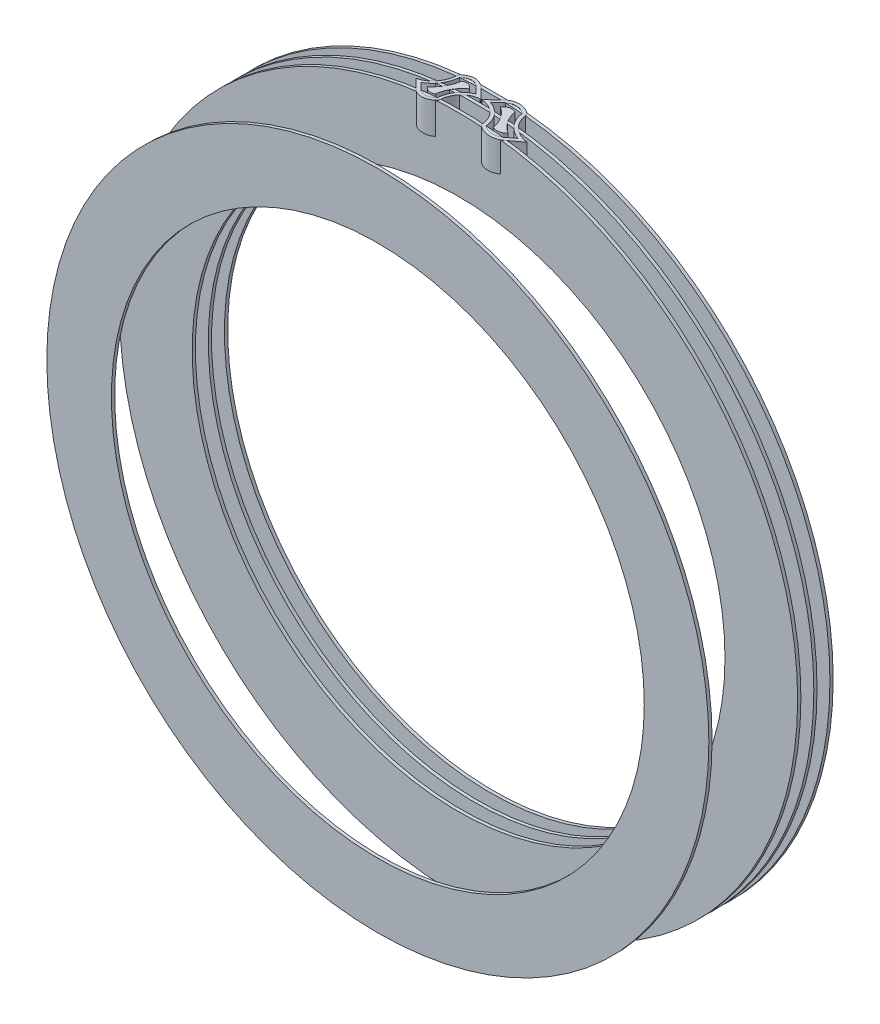
from build123d import *

# Parameters (mm, degrees)
SKETCH1_R                = 13.0175
SKETCH1_R_2              = 12.3825
SKETCH1_R_3              = 10.4775
BOSS_EXTRUDE1_DEPTH      = 0.0635
BOSS_EXTRUDE3_REACH      = 30.259
BOSS_EXTRUDE3_END_RADIUS = 13.335
SKETCH4_R                = 13.335
SKETCH4_R_2              = 10.4775
BOSS_EXTRUDE4_DEPTH      = 0.0635
SKETCH9_R                = 13.335
SKETCH9_R_2              = 10.4775
BOSS_EXTRUDE5_DEPTH      = 0.0635
SKETCH10_R               = 13.335
SKETCH10_R_2             = 10.4775
BOSS_EXTRUDE6_DEPTH      = 0.0635


with BuildPart() as part:
    # Sketch1 → Boss-Extrude1 (new, symmetric)
    with BuildSketch(Plane.XY):
        Circle(SKETCH1_R)
        Circle(SKETCH1_R_2, mode=Mode.SUBTRACT)
        Circle(SKETCH1_R_2)
        Circle(SKETCH1_R_3, mode=Mode.SUBTRACT)
    extrude(amount=BOSS_EXTRUDE1_DEPTH, both=True)


with BuildPart() as body_2:
    # Boss-Extrude3: up to this cylinder (the profile starts inside it)
    boss_extrude3_end = Plane(origin=(0, 0, -4.0107315), z_dir=(0, 0, -1)) * Cylinder(BOSS_EXTRUDE3_END_RADIUS, 89.372447, mode=Mode.PRIVATE)
    # Sketch3 → Boss-Extrude3 (new, up to the surface)
    with BuildSketch(Plane(origin=(0, 12.065, 0), x_dir=(1, 0, 0), z_dir=(0, 1, 0)), mode=Mode.PRIVATE) as boss_extrude3_sk1:
        with BuildLine():
            Line((0.460039804, 4.445004699), (0.03216311, 4.017128005))
            ThreePointArc((0.03216311, 4.017128005), (0.029324213, 4.003500425), (0.040684587, 3.995456038))
            ThreePointArc((0.040684587, 3.995456038), (0.584364457, 3.762630541), (0.830499923, 3.224845413))
            ThreePointArc((0.830499923, 3.224845413), (0.844051449, 3.175009397), (0.876325349, 3.134689828))
            ThreePointArc((0.876325349, 3.134689828), (1.310980159, 2.989724348), (1.730039804, 3.175004699))
            Line((1.730039804, 3.175004699), (2.178784076, 3.623749188))
            ThreePointArc((2.178784076, 3.623749188), (1.620796803, 3.842668346), (1.360187679, 4.382444484))
            ThreePointArc((1.360187679, 4.382444484), (1.34655763, 4.445), (1.304234905, 4.493039127))
            ThreePointArc((1.304234905, 4.493039127), (0.872979662, 4.629966452), (0.460039804, 4.445004699))
        make_face()
        with BuildLine():
            Line((1.640237243, 3.26480726), (1.9111001, 3.53567023))
            ThreePointArc((1.9111001, 3.53567023), (1.437467163, 3.85446617), (1.232813929, 4.387454034))
            ThreePointArc((1.232813929, 4.387454034), (0.885090081, 4.503426418), (0.549842365, 4.355202137))
            Line((0.549842365, 4.355202137), (0.278976021, 4.084335794))
            ThreePointArc((0.278976021, 4.084335794), (0.752610048, 3.765541996), (0.957265678, 3.232555363))
            ThreePointArc((0.957265678, 3.232555363), (1.304989527, 3.11658298), (1.640237243, 3.26480726))
        make_face(mode=Mode.SUBTRACT)
    boss_extrude3_tool1 = extrude(boss_extrude3_sk1.sketch, amount=BOSS_EXTRUDE3_REACH, mode=Mode.PRIVATE) & boss_extrude3_end
    add(boss_extrude3_tool1.solids().sort_by_distance((0.874517, 12.065, -4.602955))[0])
    # Sketch3 → Boss-Extrude3 (new, up to the surface)
    with BuildSketch(Plane(origin=(0, 12.065, 0), x_dir=(1, 0, 0), z_dir=(0, 1, 0)), mode=Mode.PRIVATE) as boss_extrude3_sk2:
        with BuildLine():
            Line((-1.730039804, 3.175004699), (-2.178784076, 3.623749188))
            ThreePointArc((-2.178784076, 3.623749188), (-1.620796803, 3.842668346), (-1.360187679, 4.382444484))
            ThreePointArc((-1.360187679, 4.382444484), (-1.34655763, 4.445), (-1.304234905, 4.493039127))
            ThreePointArc((-1.304234905, 4.493039127), (-0.872979662, 4.629966452), (-0.460039804, 4.445004699))
            Line((-0.460039804, 4.445004699), (-0.03216311, 4.017128005))
            ThreePointArc((-0.03216311, 4.017128005), (-0.029324213, 4.003500425), (-0.040684587, 3.995456038))
            ThreePointArc((-0.040684587, 3.995456038), (-0.584364457, 3.762630541), (-0.830499923, 3.224845413))
            ThreePointArc((-0.830499923, 3.224845413), (-0.844051449, 3.175009397), (-0.876325349, 3.134689828))
            ThreePointArc((-0.876325349, 3.134689828), (-1.310980159, 2.989724348), (-1.730039804, 3.175004699))
        make_face()
        with BuildLine():
            ThreePointArc((-1.232813929, 4.387454034), (-1.437467163, 3.85446617), (-1.9111001, 3.53567023))
            Line((-1.9111001, 3.53567023), (-1.640237243, 3.26480726))
            ThreePointArc((-1.640237243, 3.26480726), (-1.304989527, 3.11658298), (-0.957265678, 3.232555363))
            ThreePointArc((-0.957265678, 3.232555363), (-0.752610048, 3.765541996), (-0.278976021, 4.084335794))
            Line((-0.278976021, 4.084335794), (-0.549842365, 4.355202137))
            ThreePointArc((-0.549842365, 4.355202137), (-0.885090081, 4.503426418), (-1.232813929, 4.387454034))
        make_face(mode=Mode.SUBTRACT)
    boss_extrude3_tool2 = extrude(boss_extrude3_sk2.sketch, amount=BOSS_EXTRUDE3_REACH, mode=Mode.PRIVATE) & boss_extrude3_end
    add(boss_extrude3_tool2.solids().sort_by_distance((-1.935281, 12.065, -3.418508))[0])
    # Sketch3 → Boss-Extrude3 (new, up to the surface)
    with BuildSketch(Plane(origin=(0, 12.065, 0), x_dir=(1, 0, 0), z_dir=(0, 1, 0)), mode=Mode.PRIVATE) as boss_extrude3_sk3:
        with BuildLine():
            ThreePointArc((-1.052713427, 4.279131116), (-0.859118112, 4.309540606), (-0.684546207, 4.220498296))
            Line((-0.684546207, 4.220498296), (-0.608292834, 4.144244923))
            ThreePointArc((-0.608292834, 4.144244923), (-0.961843799, 3.801183986), (-1.137365744, 3.340878503))
            ThreePointArc((-1.137365744, 3.340878503), (-1.330961254, 3.310468752), (-1.505533401, 3.399511102))
            Line((-1.505533401, 3.399511102), (-1.581784051, 3.475761789))
            ThreePointArc((-1.581784051, 3.475761789), (-1.228233763, 3.818824337), (-1.052713427, 4.279131116))
        make_face()
    boss_extrude3_tool3 = extrude(boss_extrude3_sk3.sketch, amount=BOSS_EXTRUDE3_REACH, mode=Mode.PRIVATE) & boss_extrude3_end
    add(boss_extrude3_tool3.solids().sort_by_distance((-1.095038, 12.065, -3.810005))[0])
    # Sketch3 → Boss-Extrude3 (new, up to the surface)
    with BuildSketch(Plane(origin=(0, 12.065, 0), x_dir=(1, 0, 0), z_dir=(0, 1, 0)), mode=Mode.PRIVATE) as boss_extrude3_sk4:
        with BuildLine():
            ThreePointArc((1.052713427, 4.279131116), (0.859118112, 4.309540606), (0.684546207, 4.220498296))
            Line((0.684546207, 4.220498296), (0.608292834, 4.144244923))
            ThreePointArc((0.608292834, 4.144244923), (0.961843799, 3.801183986), (1.137365744, 3.340878503))
            ThreePointArc((1.137365744, 3.340878503), (1.330961254, 3.310468752), (1.505533401, 3.399511102))
            Line((1.505533401, 3.399511102), (1.581784051, 3.475761789))
            ThreePointArc((1.581784051, 3.475761789), (1.228233763, 3.818824337), (1.052713427, 4.279131116))
        make_face()
    boss_extrude3_tool4 = extrude(boss_extrude3_sk4.sketch, amount=BOSS_EXTRUDE3_REACH, mode=Mode.PRIVATE) & boss_extrude3_end
    add(boss_extrude3_tool4.solids().sort_by_distance((1.095038, 12.065, -3.810005))[0])


with BuildPart() as body_3:
    # Sketch4 → Boss-Extrude4 (new, symmetric)
    with BuildSketch(Plane.XY.offset(-3.175)):
        Circle(SKETCH4_R)
        Circle(SKETCH4_R_2, mode=Mode.SUBTRACT)
    extrude(amount=BOSS_EXTRUDE4_DEPTH, both=True)


with BuildPart() as body_4:
    # Sketch9 → Boss-Extrude5 (new, symmetric)
    with BuildSketch(Plane.XY.offset(-3.81)):
        Circle(SKETCH9_R)
        Circle(SKETCH9_R_2, mode=Mode.SUBTRACT)
    extrude(amount=BOSS_EXTRUDE5_DEPTH, both=True)


with BuildPart() as body_5:
    # Sketch10 → Boss-Extrude6 (new, symmetric)
    with BuildSketch(Plane.XY.offset(-4.445)):
        Circle(SKETCH10_R)
        Circle(SKETCH10_R_2, mode=Mode.SUBTRACT)
    extrude(amount=BOSS_EXTRUDE6_DEPTH, both=True)


solid = Compound([part.part, body_2.part, body_3.part, body_4.part, body_5.part])
